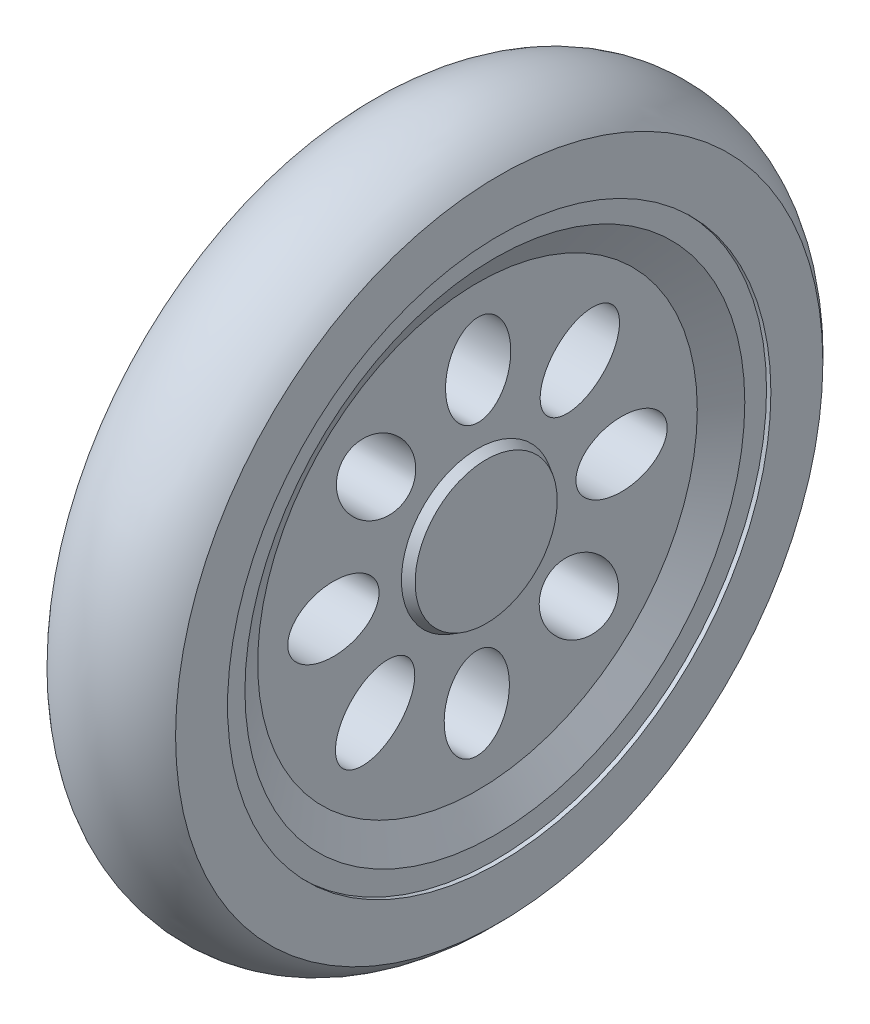
from build123d import *

# Parameters (mm, degrees)
SKETCH1_R           = 41.25
BOSS_EXTRUDE1_DEPTH = 15
SKETCH2_R           = 31.75
CUT_EXTRUDE1_DEPTH  = 0.508
SKETCH3_R           = 29.21
CUT_EXTRUDE2_DEPTH  = 2.032
CUT_EXTRUDE2_TAPER  = 60
SKETCH4_R           = 8.89
BOSS_EXTRUDE3_DEPTH = 1.016
BOSS_EXTRUDE3_TAPER = 30
SKETCH5_RX          = 5.334
SKETCH5_RY          = 3.81
CUT_EXTRUDE3_DEPTH  = 13.46
CIRPATTERN1_COUNT   = 8
SKETCH6_R           = 35.408
CUT_EXTRUDE4_DEPTH  = 2.286


with BuildPart() as part:
    # Sketch1 → Boss-Extrude1 (new body)
    with BuildSketch(Plane(origin=(0, 0, 0), x_dir=(0, 0, -1), z_dir=(1, 0, 0))):
        Circle(SKETCH1_R)
    extrude(amount=BOSS_EXTRUDE1_DEPTH)

    # Sketch2 → Cut-Extrude1 (cut)
    with BuildSketch(Plane(origin=(15, 0, 0), x_dir=(0, 0, -1), z_dir=(1, 0, 0))):
        Circle(SKETCH2_R)
    extrude(amount=-CUT_EXTRUDE1_DEPTH, mode=Mode.SUBTRACT)

    # Sketch3 → Cut-Extrude2 (cut)
    with BuildSketch(Plane(origin=(14.492, 0, 0), x_dir=(0, 0, -1), z_dir=(1, 0, 0))):
        Circle(SKETCH3_R)
    extrude(amount=-CUT_EXTRUDE2_DEPTH, taper=CUT_EXTRUDE2_TAPER, mode=Mode.SUBTRACT)

    # Sketch4 → Boss-Extrude3 (add)
    with BuildSketch(Plane(origin=(12.46, 0, 0), x_dir=(0, 0, -1), z_dir=(1, 0, 0))):
        Circle(SKETCH4_R)
    extrude(amount=BOSS_EXTRUDE3_DEPTH, taper=BOSS_EXTRUDE3_TAPER)

    # Sketch5 → Cut-Extrude3 (cut, through all)
    with BuildSketch(Plane(origin=(12.46, 0, 0), x_dir=(0, 0, -1), z_dir=(1, 0, 0))):
        with Locations(Location((0.079644617, 16.836924445), (0, 0, -90))):
            Ellipse(SKETCH5_RX, SKETCH5_RY)
    cut_extrude3 = extrude(amount=-CUT_EXTRUDE3_DEPTH, mode=Mode.SUBTRACT)

    # CirPattern1: Cut-Extrude3 ×8 about axis
    cirpattern1_axis = Axis((13.476, 0, 0), (1, 0, 0))
    for i in range(1, CIRPATTERN1_COUNT):
        add(cut_extrude3.rotate(cirpattern1_axis, i * 360 / CIRPATTERN1_COUNT), mode=Mode.SUBTRACT)

    # Sketch6 → Cut-Extrude4 (cut)
    with BuildSketch(Plane.ZY):
        Circle(SKETCH6_R)
    extrude(amount=-CUT_EXTRUDE4_DEPTH, mode=Mode.SUBTRACT)

    # Sketch7 → Cut-Revolve1 (revolve, cut)
    with BuildSketch(Plane.XY):
        with BuildLine():
            Line((7.5, 41.25), (0, 41.25))
            Line((0, 41.25), (0, 37.82380131))
            ThreePointArc((0, 37.82380131), (7.5, 41.240433802), (15, 37.82380131))
            Line((15, 37.82380131), (15, 41.25))
            Line((15, 41.25), (7.5, 41.25))
        make_face()
    revolve(axis=Axis((0, 0, 0), (1, 0, 0)), mode=Mode.SUBTRACT)


solid = part.part
